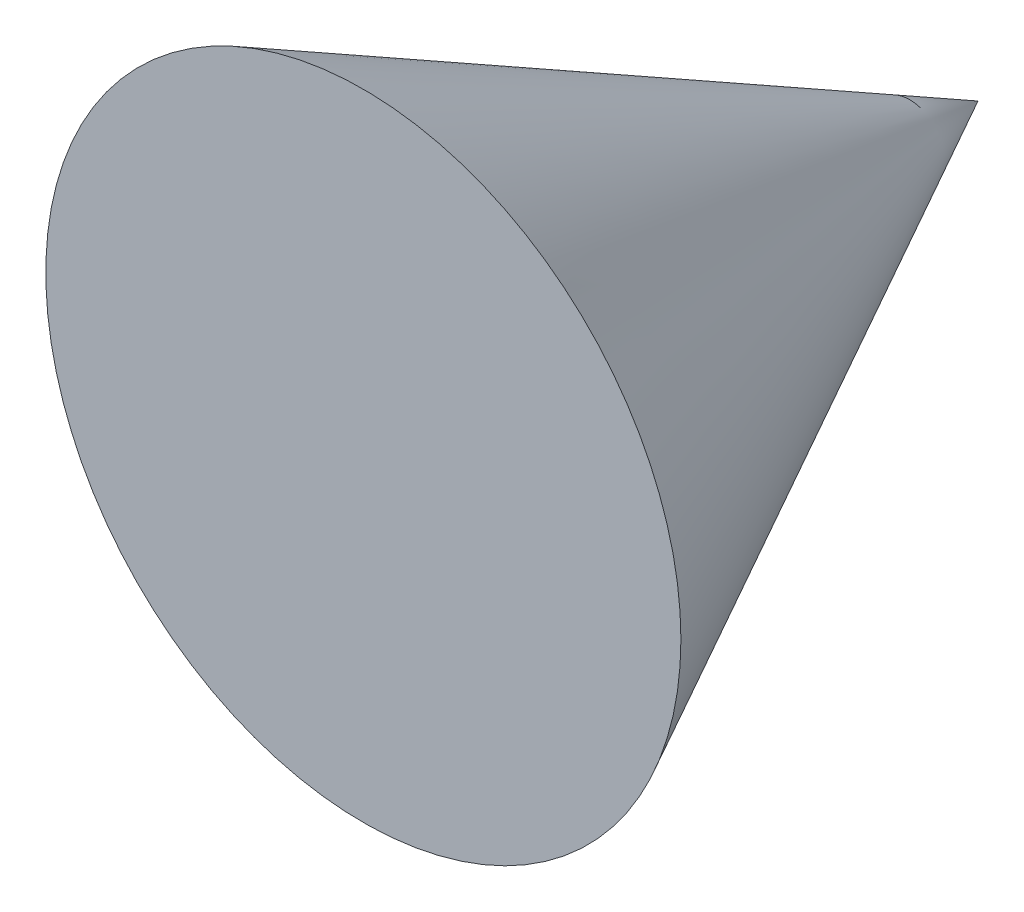
from build123d import *


with BuildPart() as part:
    # Sketch1 → Revolve1 (revolve)
    with BuildSketch(Plane(origin=(0, 0, 0), x_dir=(1, 0, 0), z_dir=(0, 1, 0))):
        Polygon((0, 0), (0, 300), (155, 0), align=None)
    revolve(axis=Axis((0, 0, 0), (0, 0, -1)))


solid = part.part
